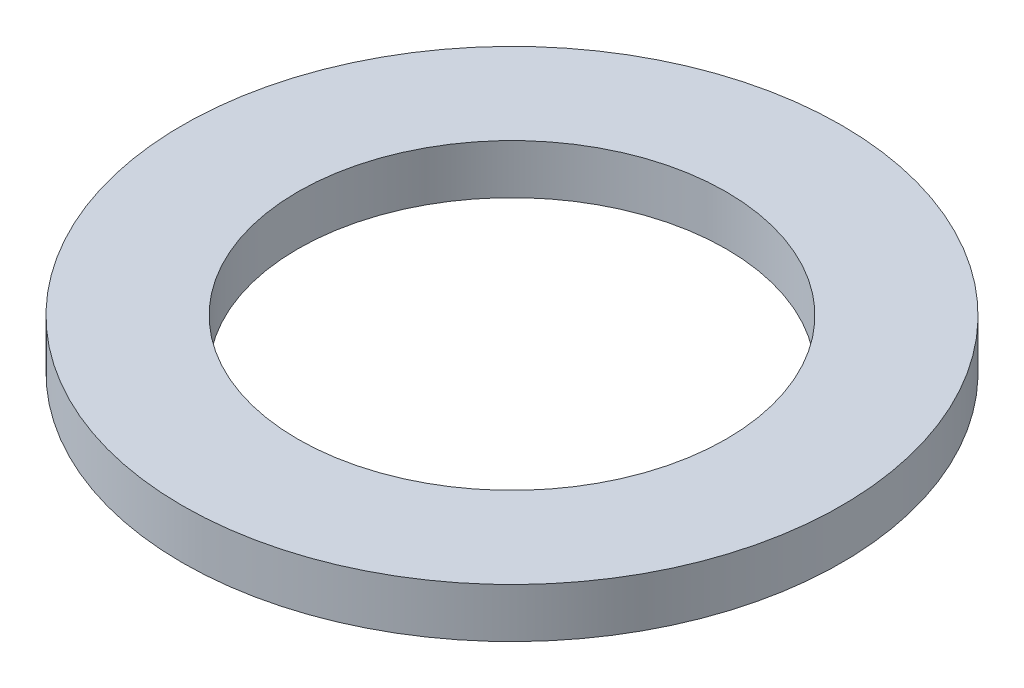
from build123d import *

# Parameters (mm, degrees)
SKETCH1_R           = 20
SKETCH1_R_2         = 13
BOSS_EXTRUDE1_DEPTH = 3


with BuildPart() as part:
    # Sketch1 → Boss-Extrude1 (new body)
    with BuildSketch(Plane(origin=(0, 0, 0), x_dir=(1, 0, 0), z_dir=(0, 1, 0))):
        Circle(SKETCH1_R)
        Circle(SKETCH1_R_2, mode=Mode.SUBTRACT)
    extrude(amount=BOSS_EXTRUDE1_DEPTH)


solid = part.part
